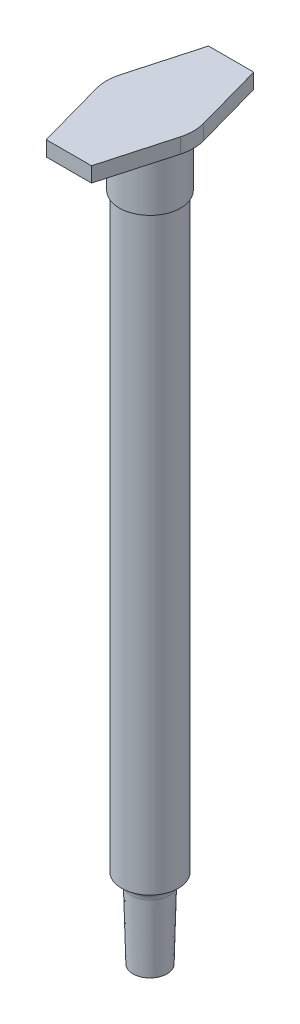
from build123d import *

# Parameters (mm, degrees)
SKETCH1_R           = 3.325
BOSS_EXTRUDE1_DEPTH = 69.2
SKETCH2_R           = 3.59
BOSS_EXTRUDE2_DEPTH = 6.82
BOSS_EXTRUDE3_DEPTH = 1.76


with BuildPart() as part:
    # Sketch1 → Boss-Extrude1 (new body)
    with BuildSketch(Plane(origin=(0, 0, 0), x_dir=(1, 0, 0), z_dir=(0, 1, 0))):
        Circle(SKETCH1_R)
    extrude(amount=BOSS_EXTRUDE1_DEPTH)

    # Sketch2 → Boss-Extrude2 (add)
    with BuildSketch(Plane(origin=(0, 69.2, 0), x_dir=(1, 0, 0), z_dir=(0, 1, 0))):
        Circle(SKETCH2_R)
    extrude(amount=BOSS_EXTRUDE2_DEPTH)

    # Sketch3 → Boss-Extrude3 (add)
    with BuildSketch(Plane(origin=(0, 76.02, 0), x_dir=(1, 0, 0), z_dir=(0, 1, 0))):
        with BuildLine():
            Line((-4.91772543, 1.370037078), (-2.65, 9.51))
            Line((-2.65, 9.51), (2.65, 9.51))
            Line((2.65, 9.51), (4.91772543, 1.370037078))
            ThreePointArc((4.91772543, 1.370037078), (5.105, 0), (4.91772543, -1.370037078))
            Line((4.91772543, -1.370037078), (2.65, -9.51))
            Line((2.65, -9.51), (-2.65, -9.51))
            Line((-2.65, -9.51), (-4.91772543, -1.370037078))
            ThreePointArc((-4.91772543, -1.370037078), (-5.105, 0), (-4.91772543, 1.370037078))
        make_face()
    extrude(amount=BOSS_EXTRUDE3_DEPTH)

    # Sketch4 → Revolve1 (revolve)
    with BuildSketch(Plane(origin=(0, 0, 0), x_dir=(0, 0, -1), z_dir=(1, 0, 0))):
        with BuildLine():
            Line((0, 0), (0, -9.35))
            Line((0, -9.35), (2, -9.35))
            Line((2, -9.35), (2.21, -1.3))
            ThreePointArc((2.21, -1.3), (2.536524, -0.451893662), (3.325, 0))
            Line((3.325, 0), (0, 0))
        make_face()
    revolve(axis=Axis((0, 0, 0), (0, -1, 0)))


solid = part.part
